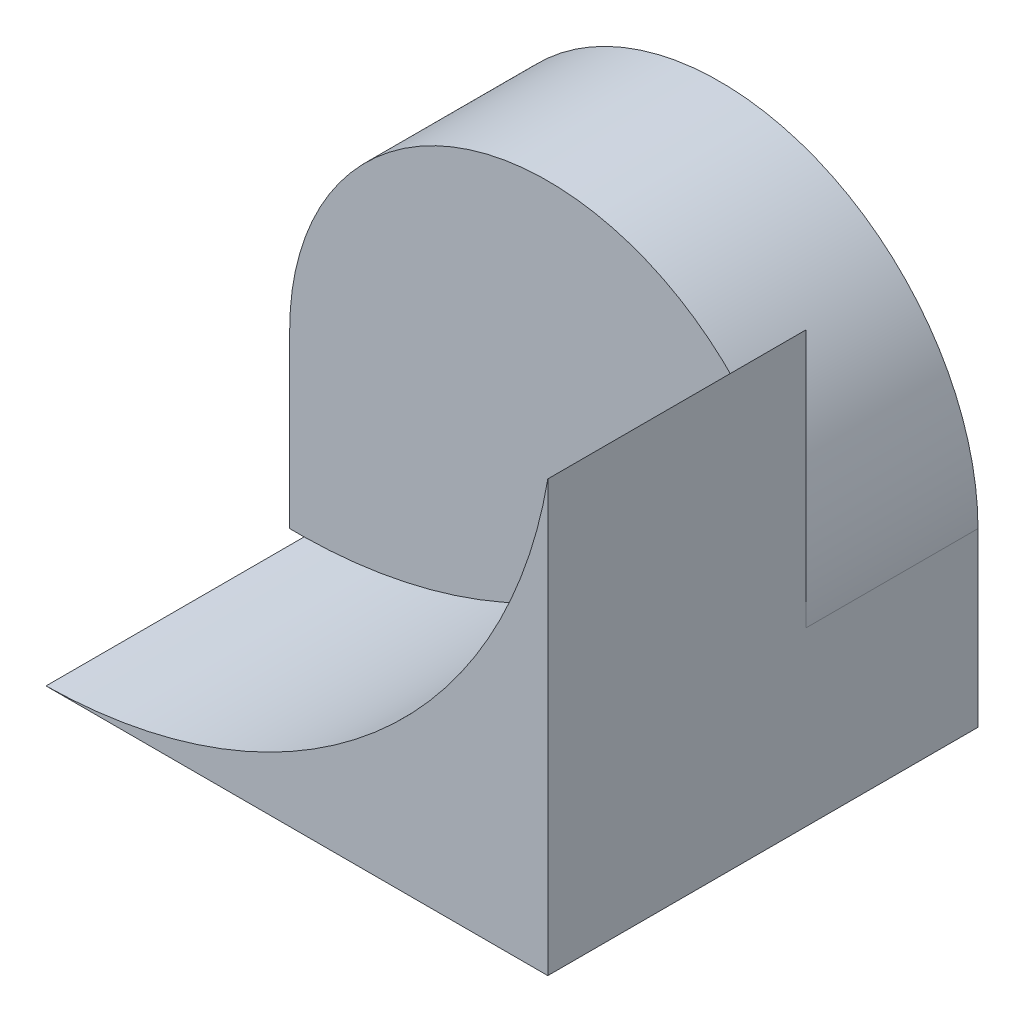
from build123d import *

# Parameters (mm, degrees)
BOSS_EXTRUDE1_DEPTH = 10
BOSS_EXTRUDE3_DEPTH = 15


with BuildPart() as part:
    # Sketch1 → Boss-Extrude1 (new body)
    with BuildSketch(Plane.XY):
        with BuildLine():
            Line((-30, 0), (-30, 10))
            ThreePointArc((-30, 10), (-15, 25), (0, 10))
            Line((0, 10), (0, 0))
            Line((0, 0), (-30, 0))
        make_face()
    extrude(amount=BOSS_EXTRUDE1_DEPTH)

    # Sketch2 → Boss-Extrude3 (add)
    with BuildSketch(Plane.XY.offset(10)):
        with BuildLine():
            ThreePointArc((0, 25), (-10.055269439, 7.220988407), (-29.161787258, 0))
            Line((-29.161787258, 0), (0, 0))
            Line((0, 0), (0, 25))
        make_face()
    extrude(amount=BOSS_EXTRUDE3_DEPTH)


solid = part.part
